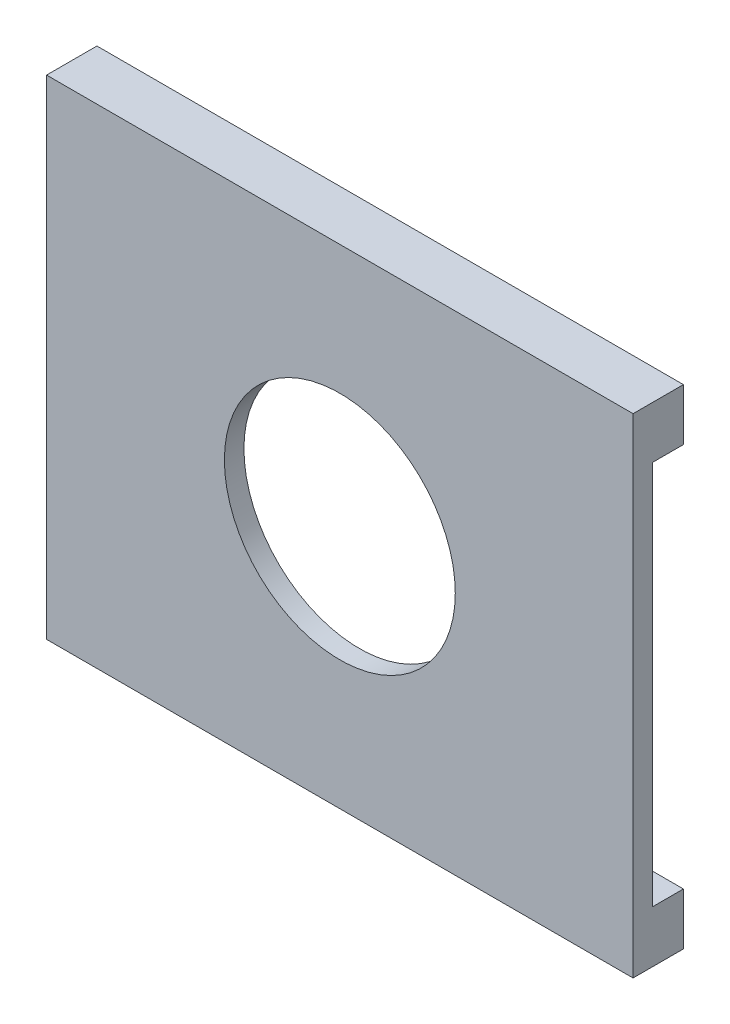
from build123d import *

# Parameters (mm, degrees)
SKETCH1_W           = 76.2
SKETCH1_H           = 63.5
BOSS_EXTRUDE1_DEPTH = 2.54
SKETCH2_W           = 76.2
SKETCH2_H           = 6.75
BOSS_EXTRUDE2_DEPTH = 4
SKETCH3_R           = 2.032
CUT_EXTRUDE1_DEPTH  = 3.81
SKETCH4_R           = 15
CUT_EXTRUDE2_DEPTH  = 10
SKETCH5_W           = 3.81
SKETCH5_H           = 10.16
BOSS_EXTRUDE3_DEPTH = 1.27


with BuildPart() as part:
    # Sketch1 → Boss-Extrude1 (new body)
    with BuildSketch(Plane.XY):
        with Locations((38.1, 31.75)):
            Rectangle(SKETCH1_W, SKETCH1_H)
    extrude(amount=BOSS_EXTRUDE1_DEPTH)

    # Sketch2 → Boss-Extrude2 (add)
    with BuildSketch(Plane(origin=(0, 0, 0), x_dir=(-1, 0, 0), z_dir=(0, 0, -1))):
        with Locations((-38.1, 60.125)):
            Rectangle(SKETCH2_W, SKETCH2_H)
        with Locations((-38.1, 3.375)):
            Rectangle(SKETCH2_W, SKETCH2_H)
    extrude(amount=BOSS_EXTRUDE2_DEPTH)

    # Sketch3 → Cut-Extrude1 (cut)
    with BuildSketch(Plane(origin=(0, 0, -4), x_dir=(-1, 0, 0), z_dir=(0, 0, -1))):
        with Locations((-63.5, 60.125)):
            Circle(SKETCH3_R)
        with Locations((-63.5, 3.375)):
            Circle(SKETCH3_R)
        with Locations((-12.7, 3.375)):
            Circle(SKETCH3_R)
        with Locations((-12.7, 60.125)):
            Circle(SKETCH3_R)
    extrude(amount=-CUT_EXTRUDE1_DEPTH, mode=Mode.SUBTRACT)

    # Sketch4 → Cut-Extrude2 (cut)
    with BuildSketch(Plane.XY.offset(2.54)):
        with Locations((38.1, 31.75)):
            Circle(SKETCH4_R)
    extrude(amount=-CUT_EXTRUDE2_DEPTH, mode=Mode.SUBTRACT)

    # Sketch5 → Boss-Extrude3 (add)
    with BuildSketch(Plane(origin=(0, 0, 0), x_dir=(-1, 0, 0), z_dir=(0, 0, -1))):
        with Locations((-26.035, 51.67)):
            Rectangle(SKETCH5_W, SKETCH5_H)
        with Locations((-26.035, 11.83)):
            Rectangle(SKETCH5_W, SKETCH5_H)
    extrude(amount=BOSS_EXTRUDE3_DEPTH)


solid = part.part
